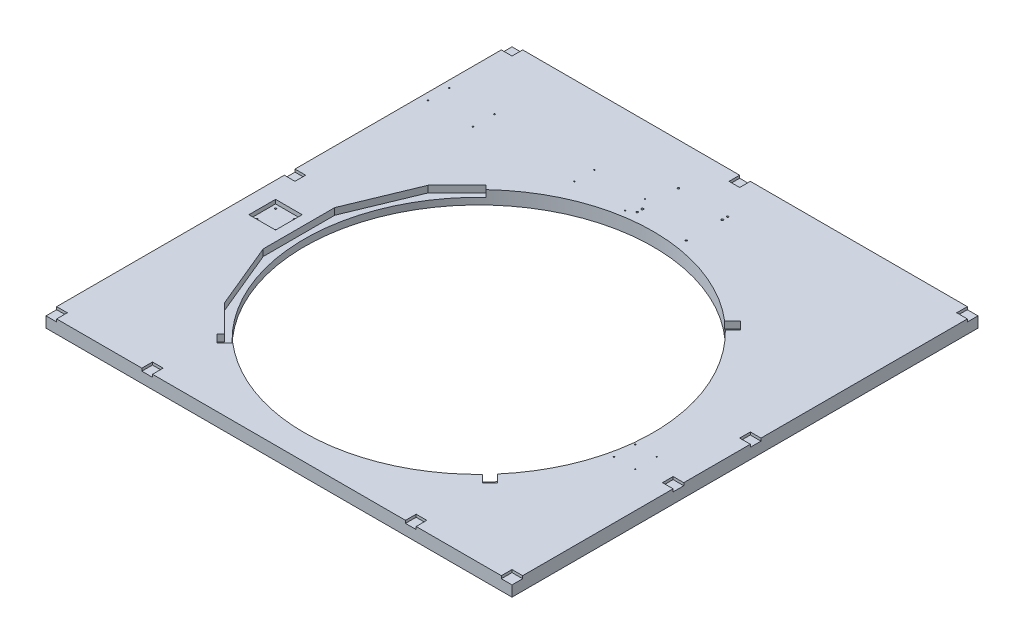
from build123d import *

# Parameters (mm, degrees)
SKETCH1_W             = 2000
SKETCH1_H             = 2000
BOSS_EXTRUDE1_DEPTH   = 50
SKETCH2_R             = 6
CUT_EXTRUDE1_DEPTH    = 30
SKETCH3_W             = 2000
SKETCH3_H             = 50
CUT_EXTRUDE2_DEPTH    = 250
SKETCH4_W             = 1750
SKETCH4_H             = 50
CUT_EXTRUDE3_DEPTH    = 125
SKETCH5_W             = 1750
SKETCH5_H             = 50
CUT_EXTRUDE4_DEPTH    = 125
SKETCH6_R             = 655
CUT_EXTRUDE5_DEPTH    = 51
SKETCH7_W             = 100
SKETCH7_H             = 100
CUT_EXTRUDE6_DEPTH    = 15
M8_TAPPED_HOLE1_D     = 6.8
M8_TAPPED_HOLE1_DEPTH = 17.707073895
M8_TAPPED_HOLE1_TIP   = 2.042926105
SKETCH13_R            = 15
SKETCH13_R_2          = 7.5
CUT_EXTRUDE8_DEPTH    = 25
SKETCH14_W            = 40
SKETCH14_H            = 40
SKETCH14_W_2          = 80
SKETCH14_H_2          = 80
CUT_EXTRUDE9_DEPTH    = 10
M5_TAPPED_HOLE1_D     = 4.2
M5_TAPPED_HOLE1_DEPTH = 12.4
M5_TAPPED_HOLE1_TIP   = 1.2618073
M8_TAPPED_HOLE2_D     = 6.8
M8_TAPPED_HOLE2_DEPTH = 19.75
M8_TAPPED_HOLE2_TIP   = 2.042926105
SKETCH21_R            = 4
CUT_EXTRUDE10_DEPTH   = 10
M6_TAPPED_HOLE1_D     = 5
M6_TAPPED_HOLE1_DEPTH = 15
M6_TAPPED_HOLE1_TIP   = 1.502151548
CUT_EXTRUDE11_DEPTH   = 25
CUT_EXTRUDE12_DEPTH   = 25


with BuildPart() as part:
    # Sketch1 → Boss-Extrude1 (new body)
    with BuildSketch(Plane(origin=(0, 0, 0), x_dir=(1, 0, 0), z_dir=(0, 1, 0))):
        Rectangle(SKETCH1_W, SKETCH1_H)
    extrude(amount=-BOSS_EXTRUDE1_DEPTH)

    # Sketch2 → Cut-Extrude1 (cut)
    with BuildSketch(Plane(origin=(0, 0, 0), x_dir=(1, 0, 0), z_dir=(0, 1, 0))):
        with Locations((0, -175)):
            Circle(SKETCH2_R)
        with Locations((106, 129)):
            Circle(SKETCH2_R)
    extrude(amount=-CUT_EXTRUDE1_DEPTH, mode=Mode.SUBTRACT)

    # Sketch3 → Cut-Extrude2 (cut)
    with BuildSketch(Plane.XY.offset(1000)):
        with Locations((0, -25)):
            Rectangle(SKETCH3_W, SKETCH3_H)
    extrude(amount=-CUT_EXTRUDE2_DEPTH, mode=Mode.SUBTRACT)

    # Sketch4 → Cut-Extrude3 (cut)
    with BuildSketch(Plane.ZY.offset(1000)):
        with Locations((-125, -25)):
            Rectangle(SKETCH4_W, SKETCH4_H)
    extrude(amount=-CUT_EXTRUDE3_DEPTH, mode=Mode.SUBTRACT)

    # Sketch5 → Cut-Extrude4 (cut)
    with BuildSketch(Plane(origin=(1000, 0, 0), x_dir=(0, 0, -1), z_dir=(1, 0, 0))):
        with Locations((125, -25)):
            Rectangle(SKETCH5_W, SKETCH5_H)
    extrude(amount=-CUT_EXTRUDE4_DEPTH, mode=Mode.SUBTRACT)

    # Sketch6 → Cut-Extrude5 (cut, through all)
    with BuildSketch(Plane(origin=(0, 0, 0), x_dir=(1, 0, 0), z_dir=(0, 1, 0))):
        Circle(SKETCH6_R)
    extrude(amount=-CUT_EXTRUDE5_DEPTH, mode=Mode.SUBTRACT)

    # Sketch7 → Cut-Extrude6 (cut)
    with BuildSketch(Plane(origin=(0, 0, 0), x_dir=(1, 0, 0), z_dir=(0, 1, 0))):
        with Locations((-763, 0)):
            Rectangle(SKETCH7_W, SKETCH7_H)
    extrude(amount=-CUT_EXTRUDE6_DEPTH, mode=Mode.SUBTRACT)

    # M8 Tapped Hole1
    with Locations(Plane(origin=(0, -15, 0), x_dir=(1, 0, 0), z_dir=(0, 1, 0))):
        with Locations((-798, 35), (-798, -35), (-728, -35), (-728, 35)):
            Hole(M8_TAPPED_HOLE1_D / 2, depth=M8_TAPPED_HOLE1_DEPTH)
            with Locations((0, 0, -(M8_TAPPED_HOLE1_DEPTH + M8_TAPPED_HOLE1_TIP / 2))):  # 118° drill point
                Cone(0, M8_TAPPED_HOLE1_D / 2, M8_TAPPED_HOLE1_TIP, mode=Mode.SUBTRACT)

    # Sketch13 → Cut-Extrude8 (cut)
    with BuildSketch(Plane.XZ.offset(50)):
        with Locations((-835, 710)):
            Circle(SKETCH13_R)
        with Locations((835, -960)):
            Circle(SKETCH13_R)
        with Locations((835, 710)):
            Circle(SKETCH13_R)
        with Locations((-835, -960)):
            Circle(SKETCH13_R)
        with Locations((0, -960)):
            Circle(SKETCH13_R_2)
        with Locations((0, 710)):
            Circle(SKETCH13_R_2)
        with Locations((835, -125)):
            Circle(SKETCH13_R_2)
        with Locations((-835, -125)):
            Circle(SKETCH13_R_2)
    extrude(amount=-CUT_EXTRUDE8_DEPTH, mode=Mode.SUBTRACT)

    # Sketch14 → Cut-Extrude9 (cut)
    with BuildSketch(Plane(origin=(0, 0, 0), x_dir=(1, 0, 0), z_dir=(0, 1, 0))):
        with Locations((855, -730)):
            Rectangle(SKETCH14_W, SKETCH14_H)
        with Locations((875, 165)):
            Rectangle(SKETCH14_W_2, SKETCH14_H)
        with Locations((855, 980)):
            Rectangle(SKETCH14_W, SKETCH14_H)
        with Locations((-855, 980)):
            Rectangle(SKETCH14_W, SKETCH14_H)
        with Locations((-855, -730)):
            Rectangle(SKETCH14_W, SKETCH14_H)
        with Locations((-875, 165)):
            Rectangle(SKETCH14_W_2, SKETCH14_H)
        with Locations((0, 1000)):
            Rectangle(SKETCH14_W, SKETCH14_H_2)
        with Locations((-495, -750)):
            Rectangle(SKETCH14_W, SKETCH14_H_2)
        with Locations((495, -750)):
            Rectangle(SKETCH14_W, SKETCH14_H_2)
        with Locations((875, -125)):
            Rectangle(SKETCH14_W_2, SKETCH14_H)
    extrude(amount=-CUT_EXTRUDE9_DEPTH, mode=Mode.SUBTRACT)

    # M5 Tapped Hole1
    with Locations(Plane(origin=(0, 0, 0), x_dir=(1, 0, 0), z_dir=(0, 1, 0))):
        with Locations((740, -152), (740, -72), (660, -72), (660, -152), (-310.091163632, 744.682016608), (-310.091163632, 669.682016608), (-120.091163632, 669.682016608), (-120.091163632, 744.682016608)):
            Hole(M5_TAPPED_HOLE1_D / 2, depth=M5_TAPPED_HOLE1_DEPTH)
            with Locations((0, 0, -(M5_TAPPED_HOLE1_DEPTH + M5_TAPPED_HOLE1_TIP / 2))):  # 118° drill point
                Cone(0, M5_TAPPED_HOLE1_D / 2, M5_TAPPED_HOLE1_TIP, mode=Mode.SUBTRACT)

    # M8 Tapped Hole2
    with Locations(Plane(origin=(0, 0, 0), x_dir=(1, 0, 0), z_dir=(0, 1, 0))):
        with Locations((-92.500000018, 687.499999989), (92.500000005, 687.499999992), (92.500000005, 842.499999992), (-92.499999995, 842.499999992)):
            Hole(M8_TAPPED_HOLE2_D / 2, depth=M8_TAPPED_HOLE2_DEPTH)
            with Locations((0, 0, -(M8_TAPPED_HOLE2_DEPTH + M8_TAPPED_HOLE2_TIP / 2))):  # 118° drill point
                Cone(0, M8_TAPPED_HOLE2_D / 2, M8_TAPPED_HOLE2_TIP, mode=Mode.SUBTRACT)

    # Sketch21 → Cut-Extrude10 (cut)
    with BuildSketch(Plane(origin=(0, 0, 0), x_dir=(1, 0, 0), z_dir=(0, 1, 0))):
        with Locations((-92.500000018, 707.499999987)):
            Circle(SKETCH21_R)
        with Locations((92.500000005, 822.499999992)):
            Circle(SKETCH21_R)
    extrude(amount=-CUT_EXTRUDE10_DEPTH, mode=Mode.SUBTRACT)

    # M6 Tapped Hole1
    with Locations(Plane(origin=(0, 0, 0), x_dir=(1, 0, 0), z_dir=(0, 1, 0))):
        with Locations((-678.5, 738), (-678.5, 656.604373077), (-848.5, 658), (-848.5, 738)):
            Hole(M6_TAPPED_HOLE1_D / 2, depth=M6_TAPPED_HOLE1_DEPTH)
            with Locations((0, 0, -(M6_TAPPED_HOLE1_DEPTH + M6_TAPPED_HOLE1_TIP / 2))):  # 118° drill point
                Cone(0, M6_TAPPED_HOLE1_D / 2, M6_TAPPED_HOLE1_TIP, mode=Mode.SUBTRACT)

    # Sketch25 → Cut-Extrude11 (cut)
    with BuildSketch(Plane(origin=(0, 0, 0), x_dir=(1, 0, 0), z_dir=(0, 1, 0))):
        with BuildLine():
            Line((-555.28218759, -371.027695765), (-456.083873865, -470.226009489))
            Line((-456.083873865, -470.226009489), (-425.26997323, -439.412108854))
            ThreePointArc((-425.26997323, -439.412108854), (-611.483880806, 5.001505042), (-418.025396439, 446.309667686))
            Line((-418.025396439, 446.309667686), (-449.012806053, 477.297077301))
            Line((-449.012806053, 477.297077301), (-555.28218759, 371.027695765))
            Line((-555.28218759, 371.027695765), (-655, 130.287600634))
            Line((-655, 130.287600634), (-655, -130.287600634))
            Line((-655, -130.287600634), (-555.28218759, -371.027695765))
        make_face()
        Polygon((-675, -134.265847981), (-572.23736889, -382.356785712), (-470.226009489, -484.368145113), (-456.083873865, -470.226009489), (-555.28218759, -371.027695765), (-655, -130.287600634), (-655, 130.287600634), (-555.28218759, 371.027695765), (-449.012806053, 477.297077301), (-463.154941677, 491.439212925), (-572.23736889, 382.356785712), (-675, 134.265847981), align=None)
    extrude(amount=-CUT_EXTRUDE11_DEPTH, mode=Mode.SUBTRACT)

    # Sketch26 → Cut-Extrude12 (cut)
    with BuildSketch(Plane(origin=(0, 0, 0), x_dir=(1, 0, 0), z_dir=(0, 1, 0))):
        Polygon((-484.368145113, -498.510280737), (-456.083873865, -470.226009489), (-420.576835046, -491.287513165), (-456.083873865, -526.794551984), align=None)
        Polygon((526.794551984, -456.083873865), (491.287513165, -420.576835046), (470.226009489, -456.083873865), (498.510280737, -484.368145113), align=None)
        Polygon((456.083873865, 526.794551984), (420.576835046, 491.287513165), (456.083873865, 470.226009489), (484.368145113, 498.510280737), align=None)
    extrude(amount=-CUT_EXTRUDE12_DEPTH, mode=Mode.SUBTRACT)


solid = part.part
